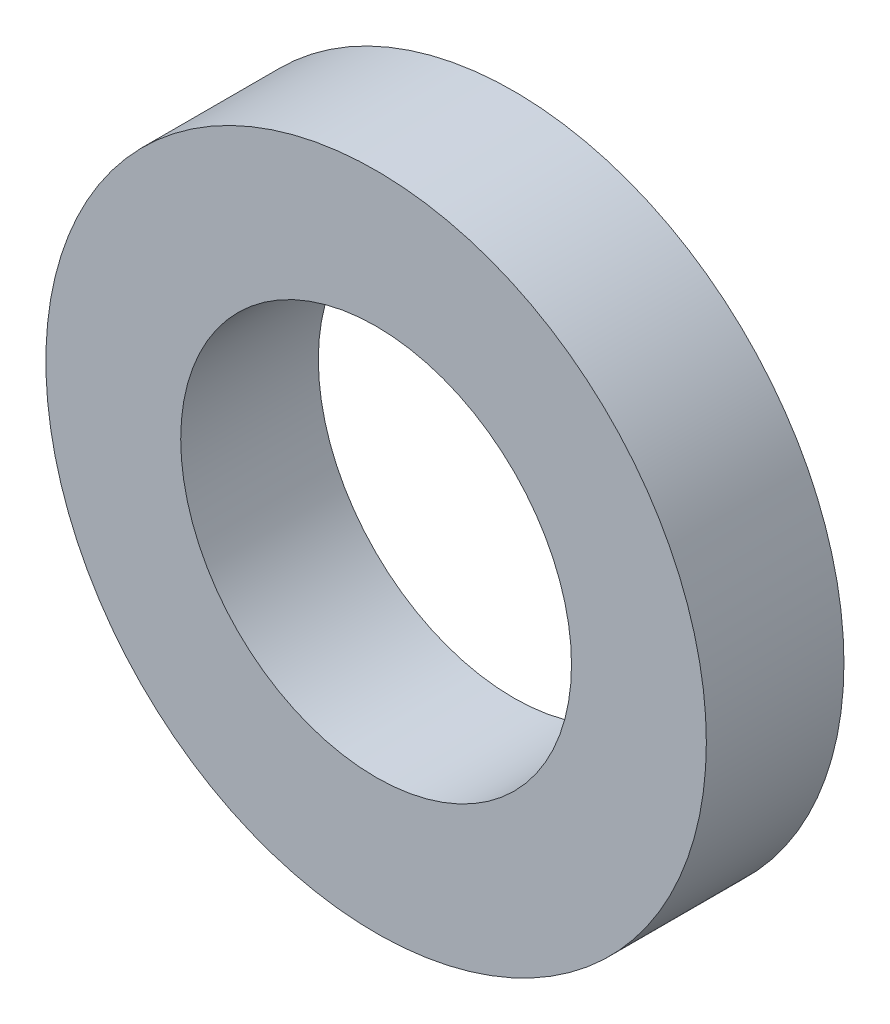
from build123d import *

# Parameters (mm, degrees)
SKETCH1_R           = 6
SKETCH1_R_2         = 3.55
BOSS_EXTRUDE1_DEPTH = 2.5


with BuildPart() as part:
    # Sketch1 → Boss-Extrude1 (new body)
    with BuildSketch(Plane.XY):
        Circle(SKETCH1_R)
        Circle(SKETCH1_R_2, mode=Mode.SUBTRACT)
    extrude(amount=BOSS_EXTRUDE1_DEPTH)


solid = part.part
